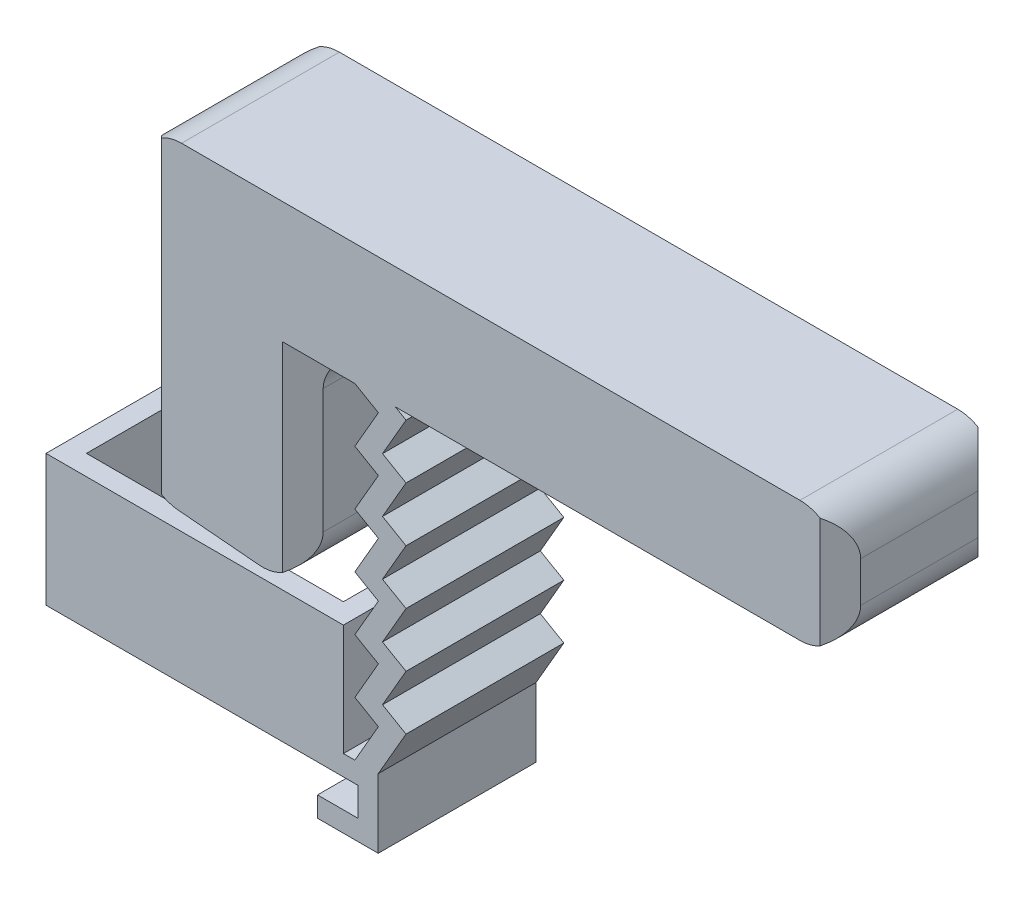
from build123d import *

# Parameters (mm, degrees)
BOSS_EXTRUDE3_DEPTH = 6.5
BOSS_EXTRUDE4_DEPTH = 7.8
CHAMFER1_SIZE       = 1
FILLET1_R           = 2


with BuildPart() as part:
    # Sketch2 → Boss-Extrude3 (new body)
    with BuildSketch(Plane(origin=(0, 0, 0), x_dir=(1, 0, 0), z_dir=(0, 1, 0))):
        Polygon((30.214970749, 56.232123089), (30.214970749, 50.432123089), (17.514970749, 50.432123089), (17.514970749, 56.232123089), (19.514970749, 56.232123089), (19.514970749, 57.232123089), (16.514970749, 57.232123089), (16.514970749, 49.432123089), (31.214970749, 49.432123089), (31.214970749, 57.232123089), (28.214970749, 57.232123089), (28.214970749, 56.232123089), align=None)
    extrude(amount=BOSS_EXTRUDE3_DEPTH)

    # Sketch1 → Boss-Extrude4 (add)
    with BuildSketch(Plane(origin=(-49.432123089, 0, -49.432123089), x_dir=(1, 0, 0), z_dir=(0, 0, 1))):
        Polygon((82.376068434, 3.015544457), (81.2123933, 1), (80.647093838, 1), (80.647093838, 0), (81.367093838, 0), (81.367093838, -1.41), (79.367093838, -1.41), (79.367093838, -2.41), (82.367093838, -2.41), (82.367093838, 1), (83.742093838, 3.38156986), (82.578418703, 4.053418013), (83.742093838, 6.068962469), (82.578418703, 6.740810621), (83.742093838, 8.756355078), (82.578418703, 9.42820323), (83.742093838, 11.443747687), (82.578418703, 12.115595839), (83.742093838, 14.131140296), (82.578418703, 14.802988448), (83.742093838, 16.818532905), (83.2123933, 17.124355653), (105.2123933, 17.124355653), (105.2123933, 23.124355653), (70.647093838, 23.124355653), (70.647093838, 7.499909308), (78.647093838, 6.8), (78.647093838, 17.124355653), (81.2123933, 17.124355653), (82.376068434, 16.452507501), (81.2123933, 14.436963044), (82.376068434, 13.765114892), (81.2123933, 11.749570435), (82.376068434, 11.077722283), (81.2123933, 9.062177826), (82.376068434, 8.390329674), (81.2123933, 6.374785218), (82.376068434, 5.702937065), (81.2123933, 3.687392609), align=None)
    extrude(amount=-BOSS_EXTRUDE4_DEPTH)

    # Chamfer1
    chamfer1_edges = [part.edges().sort_by_distance(p)[0] for p in [
        (29.214970749, 11.962177826, -49.432123089),
        (21.214970749, 15.312132481, -49.432123089),
        (55.780270211, 20.124355653, -49.432123089),
        (29.214970749, 11.962177826, -57.232123089),
        (21.214970749, 15.312132481, -57.232123089),
        (55.780270211, 20.124355653, -57.232123089),
    ]]
    chamfer(chamfer1_edges, length=CHAMFER1_SIZE)

    # Fillet1
    fillet1_edges = [part.edges().sort_by_distance(p)[0] for p in [
        (29.214970749, 6.8, -53.332123089),
        (29.214970749, 17.124355653, -53.332123089),
        (21.214970749, 7.499909308, -53.332123089),
        (21.214970749, 23.124355653, -53.332123089),
        (55.780270211, 17.124355653, -53.332123089),
        (55.780270211, 23.124355653, -53.332123089),
    ]]
    fillet(fillet1_edges, radius=FILLET1_R)


solid = part.part
